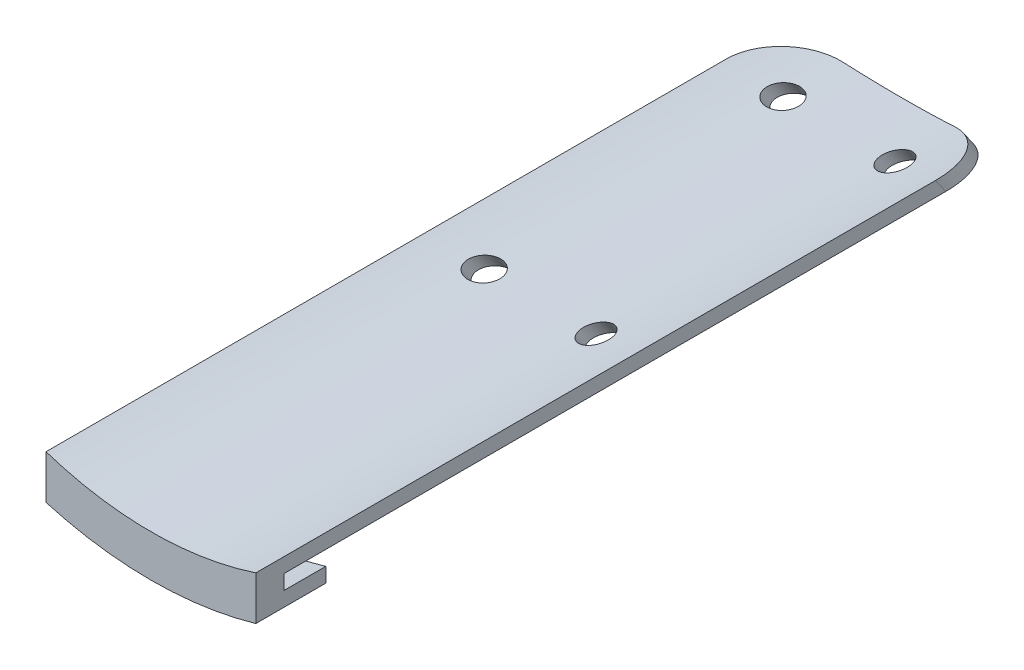
from build123d import *

# Parameters (mm, degrees)
BOSS_EXTRUDE1_DEPTH     = 161.208217
BOSS_EXTRUDE2_DEPTH     = 4
BOSS_EXTRUDE3_DEPTH     = 10
BOSS_EXTRUDE4_DEPTH     = 4
SKETCH6_R               = 2
CUT_EXTRUDE1_DEPTH      = 74.097308941
CUT_EXTRUDE1_DEPTH_BACK = 66.896441548


with BuildPart() as part:
    # Sketch1 → Boss-Extrude1 (new body)
    with BuildSketch(Plane.XY):
        with BuildLine():
            Line((50, 64.298335316), (48, 64.298335316))
            ThreePointArc((48, 64.298335316), (0, 16.298335316), (-48, 64.298335316))
            Line((-48, 64.298335316), (-50, 64.298335316))
            ThreePointArc((-50, 64.298335316), (0, 14.298335316), (50, 64.298335316))
        make_face()
    extrude(amount=BOSS_EXTRUDE1_DEPTH)

    # Sketch3 → Boss-Extrude2 (add)
    with BuildSketch(Plane.XY.offset(161.208216537)):
        with BuildLine():
            Line((50, 64.298335316), (48, 64.298335316))
            ThreePointArc((48, 64.298335316), (0, 16.298335316), (-48, 64.298335316))
            Line((-48, 64.298335316), (-50, 64.298335316))
            ThreePointArc((-50, 64.298335316), (0, 14.298335316), (50, 64.298335316))
        make_face()
    extrude(amount=BOSS_EXTRUDE2_DEPTH)



with BuildPart() as body_2:
    # Sketch4 → Boss-Extrude3 (new body)
    with BuildSketch(Plane.XY.offset(165.208216537)):
        with BuildLine():
            Line((-54, 64.298335316), (-52, 64.298335316))
            ThreePointArc((-52, 64.298335316), (0, 12.298335316), (52, 64.298335316))
            Line((52, 64.298335316), (54, 64.298335316))
            ThreePointArc((54, 64.298335316), (0, 10.298335316), (-54, 64.298335316))
        make_face()
    extrude(amount=-BOSS_EXTRUDE3_DEPTH)


with BuildPart() as part_1:
    add(part.part)

    add(body_2.part)  # Boss-Extrude4 merges body 2
    # Sketch5 → Boss-Extrude4 (add)
    with BuildSketch(Plane.XY.offset(165.208216537)):
        with BuildLine():
            Line((-50, 64.298335316), (-52, 64.298335316))
            ThreePointArc((-52, 64.298335316), (0, 12.298335316), (52, 64.298335316))
            Line((52, 64.298335316), (50, 64.298335316))
            ThreePointArc((50, 64.298335316), (0, 14.298335316), (-50, 64.298335316))
        make_face()
    extrude(amount=-BOSS_EXTRUDE4_DEPTH)

    # Sketch6 → Cut-Extrude1 (cut, two sides)
    with BuildSketch(Plane(origin=(0, 66.78809677, 46.765528821), x_dir=(-1, 0, 0), z_dir=(0, -0.819152044, -0.573576436))) as cut_extrude1_sk:
        with Locations((-8, -80)):
            Circle(SKETCH6_R)
        with Locations((8, -80)):
            Circle(SKETCH6_R)
        with Locations((8, -45)):
            Circle(SKETCH6_R)
        with Locations((-8, -45)):
            Circle(SKETCH6_R)
        with BuildLine():
            Line((-15, -128.204829529), (-15, -45))
            ThreePointArc((-15, -45), (-12.949747468, -40.050252532), (-8, -38))
            Line((-8, -38), (8, -38))
            ThreePointArc((8, -38), (12.949747468, -40.050252532), (15, -45))
            Line((15, -45), (15, -128.204829529))
            add(Edge.make_bspline(
                [(15, -128.204829529), (54, -121.736527083), (54, -98.450638275)],
                knots=[1.8522764, 1.8522764, 1.8522764, 3.141592654, 3.141592654, 3.141592654], degree=2, weights=[1, 0.799305254, 1]))
            Line((54, -98.450638275), (54, 36.880010034))
            Line((54, 36.880010034), (-54, 36.880010034))
            Line((-54, 36.880010034), (-54, -98.450638275))
            add(Edge.make_bspline(
                [(-54, -98.450638275), (-54, -121.736527083), (-15, -128.204829529)],
                knots=[0, 0, 0, 1.289316254, 1.289316254, 1.289316254], degree=2, weights=[1, 0.799305254, 1]))
        make_face()
    extrude(amount=CUT_EXTRUDE1_DEPTH, mode=Mode.SUBTRACT)
    extrude(cut_extrude1_sk.sketch, amount=-CUT_EXTRUDE1_DEPTH_BACK, mode=Mode.SUBTRACT)


solid = part_1.part
